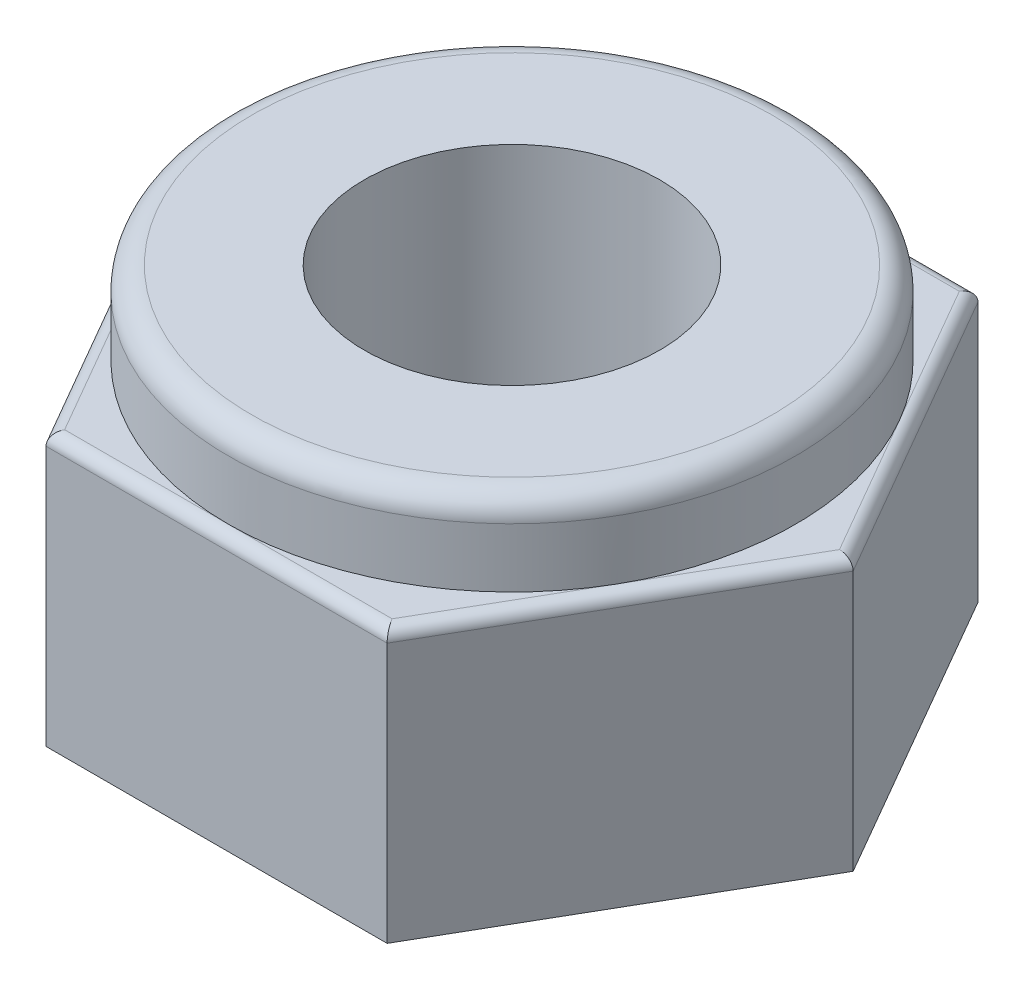
from build123d import *

# Parameters (mm, degrees)
EXTRUDE_1_DEPTH     = 2.3
FILLET_1_R          = 0.1
SKETCH_2_R          = 2.4
EXTRUDE_2_DEPTH     = 3
FILLET_2_R          = 0.2
SKETCH_3_R          = 1.25
CUT_EXTRUDE_1_DEPTH = 12.8


with BuildPart() as part:
    # 草图1 → 凸台-拉伸1 (new body)
    with BuildSketch(Plane(origin=(0, 0, 0), x_dir=(1, 0, 0), z_dir=(0, 1, 0))):
        Polygon((1.443375673, -2.5), (2.886751346, 0), (1.443375673, 2.5), (-1.443375673, 2.5), (-2.886751346, 0), (-1.443375673, -2.5), align=None)
    extrude(amount=EXTRUDE_1_DEPTH)

    # 圆角1
    fillet_1_edges = [part.edges().sort_by_distance(p)[0] for p in [
        (2.165063509, 2.3, -1.25),
        (0, 2.3, -2.5),
        (-2.165063509, 2.3, -1.25),
        (-2.165063509, 2.3, 1.25),
        (0, 2.3, 2.5),
        (2.165063509, 2.3, 1.25),
    ]]
    fillet(fillet_1_edges, radius=FILLET_1_R)

    # 草图2 → 凸台-拉伸2 (add)
    with BuildSketch(Plane.XZ):
        Circle(SKETCH_2_R)
    extrude(amount=-EXTRUDE_2_DEPTH)

    # 圆角2
    fillet_2_edges = [part.edges().sort_by_distance(p)[0] for p in [
        (-2.4, 3, 0),
    ]]
    fillet(fillet_2_edges, radius=FILLET_2_R)

    # 草图3 → 切除-拉伸1 (cut)
    with BuildSketch(Plane.XZ):
        Circle(SKETCH_3_R)
    extrude(amount=-CUT_EXTRUDE_1_DEPTH, mode=Mode.SUBTRACT)


solid = part.part
